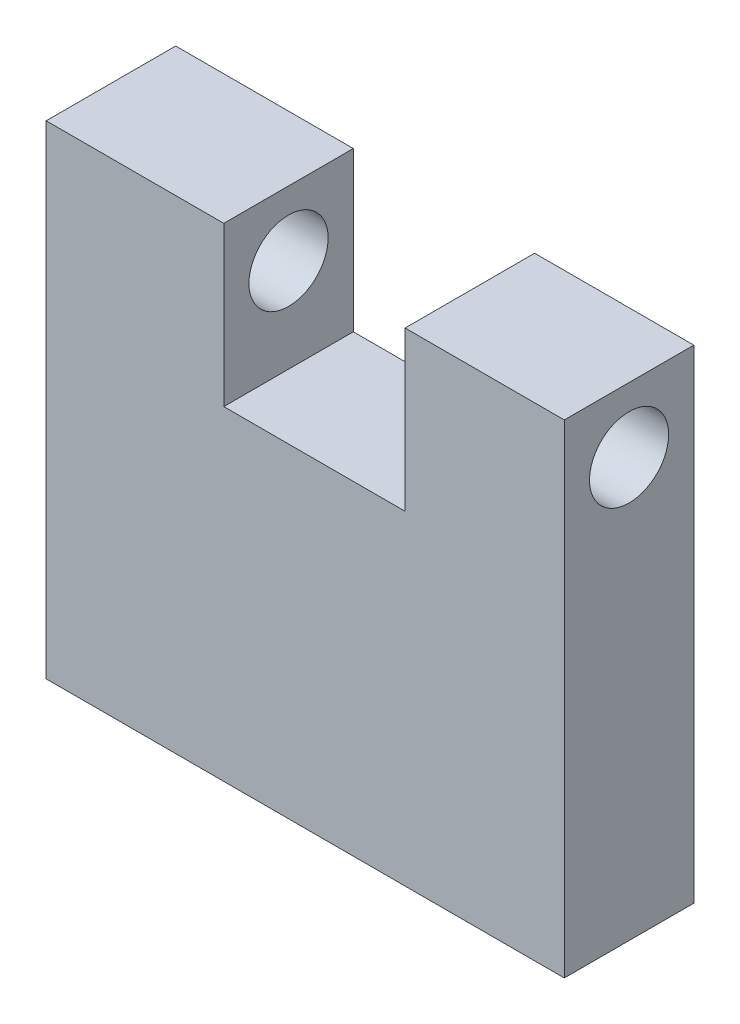
from build123d import *

# Parameters (mm, degrees)
BOSS_EXTRUDE1_DEPTH = 2.286
SKETCH3_R           = 1.397
CUT_EXTRUDE1_DEPTH  = 19.288


with BuildPart() as part:
    # Sketch1 → Boss-Extrude1 (new body, symmetric)
    with BuildSketch(Plane.XY):
        Polygon((9.83079784, -10.569522716), (-8.45720216, -10.569522716), (-8.45720216, 6.49008613), (-2.188628559, 6.49008613), (-2.188628559, 0.887867874), (4.211173098, 0.887867874), (4.211173098, 6.49008613), (9.83079784, 6.49008613), align=None)
    extrude(amount=BOSS_EXTRUDE1_DEPTH, both=True)

    # Sketch3 → Cut-Extrude1 (cut, through all)
    with BuildSketch(Plane(origin=(9.83079784, 0, 0), x_dir=(0, 0, -1), z_dir=(1, 0, 0))):
        with Locations((0, 4.20408613)):
            Circle(SKETCH3_R)
    extrude(amount=-CUT_EXTRUDE1_DEPTH, mode=Mode.SUBTRACT)


solid = part.part
